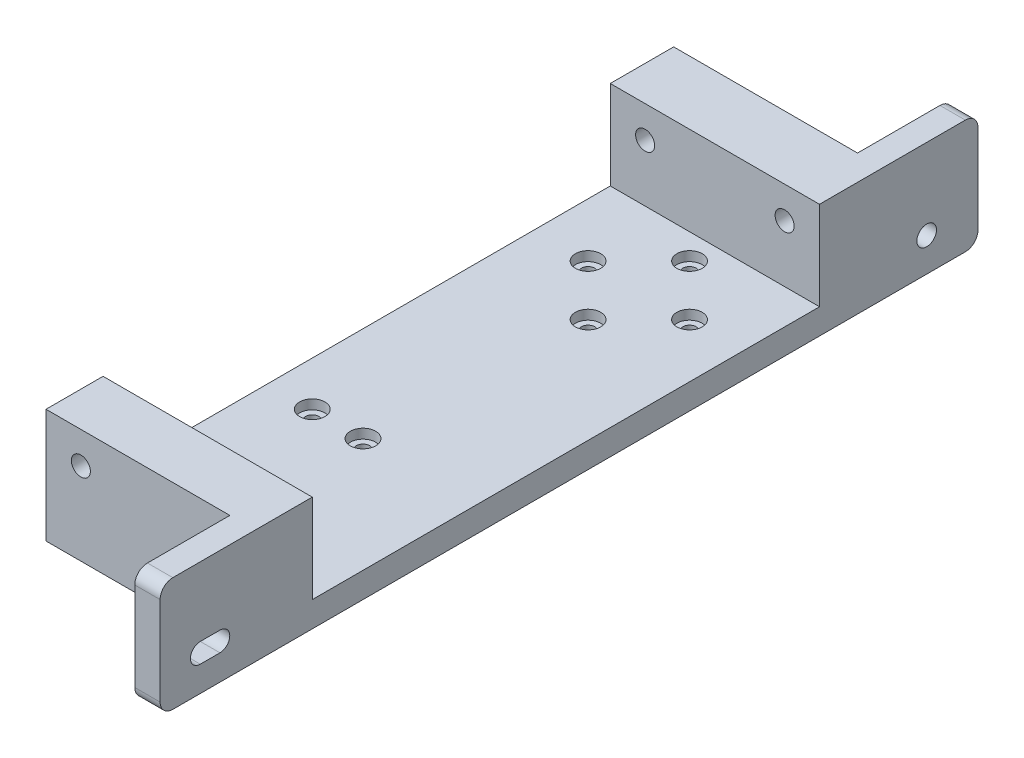
from build123d import *

# Parameters (mm, degrees)
SKETCH1_W            = 25
SKETCH1_H            = 34
BOSS_EXTRUDE2_DEPTH  = 4
SKETCH2_R            = 1.5
BOSS_EXTRUDE3_DEPTH  = 5
SKETCH3_R            = 1.5
BOSS_EXTRUDE4_DEPTH  = 2
SKETCH5_W            = 25
SKETCH5_H            = 4
BOSS_EXTRUDE5_DEPTH  = 55
SKETCH6_R            = 1.5
SKETCH6_W            = 25
SKETCH6_H            = 4
BOSS_EXTRUDE6_DEPTH  = 4
SKETCH7_W            = 4
SKETCH7_H            = 80
BOSS_EXTRUDE7_DEPTH  = 4
CUT_EXTRUDE2_DEPTH   = 5
SKETCH10_R           = 2
CUT_EXTRUDE3_DEPTH   = 1.5
SKETCH11_R           = 2
CUT_EXTRUDE4_DEPTH   = 1.5
SKETCH14_W           = 20
SKETCH14_H           = 18
BOSS_EXTRUDE8_DEPTH  = 4
SKETCH15_W           = 5
SKETCH15_H           = 18
BOSS_EXTRUDE9_DEPTH  = 29
SKETCH6_3_R          = 1.5
CUT_EXTRUDE5_DEPTH   = 35
FILLET2_R            = 2
SKETCH16_W           = 20
SKETCH16_H           = 18
BOSS_EXTRUDE10_DEPTH = 4
BOSS_EXTRUDE11_REACH = 35
SKETCH17_W           = 5
SKETCH17_H           = 18
FILLET3_R            = 2
SKETCH18_R           = 1.55
CUT_EXTRUDE6_DEPTH   = 5


with BuildPart() as part:
    # Sketch1 → Boss-Extrude2 (new body)
    with BuildSketch(Plane(origin=(0, 0, 0), x_dir=(1, 0, 0), z_dir=(0, 1, 0))):
        with Locations((12.5, -17)):
            Rectangle(SKETCH1_W, SKETCH1_H)
        with BuildLine():
            ThreePointArc((20.5, -15.95), (19.45, -17), (20.5, -18.05))
            ThreePointArc((20.5, -18.05), (21.55, -17), (20.5, -15.95))
        make_face(mode=Mode.SUBTRACT)
        with BuildLine():
            ThreePointArc((12.5, -26.05), (13.55, -25), (12.5, -23.95))
            ThreePointArc((12.5, -23.95), (11.45, -25), (12.5, -26.05))
        make_face(mode=Mode.SUBTRACT)
        with BuildLine():
            ThreePointArc((4.5, -15.95), (3.45, -17), (4.5, -18.05))
            ThreePointArc((4.5, -18.05), (5.55, -17), (4.5, -15.95))
        make_face(mode=Mode.SUBTRACT)
        with BuildLine():
            ThreePointArc((12.5, -7.95), (11.45, -9), (12.5, -10.05))
            ThreePointArc((12.5, -10.05), (13.55, -9), (12.5, -7.95))
        make_face(mode=Mode.SUBTRACT)
    extrude(amount=BOSS_EXTRUDE2_DEPTH)

    # Sketch2 → Boss-Extrude3 (add)
    with BuildSketch(Plane(origin=(0, 0, 0), x_dir=(-1, 0, 0), z_dir=(0, 0, -1))):
        Polygon((-25, 0), (0, 0), (4, 0), (4, 18), (-29, 18), (-29, 0), align=None)
        with Locations((-23.5, 13)):
            Circle(SKETCH2_R, mode=Mode.SUBTRACT)
        with Locations((-1.5, 13)):
            Circle(SKETCH2_R, mode=Mode.SUBTRACT)
    extrude(amount=-BOSS_EXTRUDE3_DEPTH)

    # Sketch3 → Boss-Extrude4 (add)
    with BuildSketch(Plane(origin=(0, 0, 0), x_dir=(-1, 0, 0), z_dir=(0, 0, -1))):
        with Locations((-1.5, 13)):
            Circle(SKETCH3_R)
        with Locations((-23.5, 13)):
            Circle(SKETCH3_R)
    extrude(amount=-BOSS_EXTRUDE4_DEPTH)

    # Sketch5 → Boss-Extrude5 (add)
    with BuildSketch(Plane.XY.offset(34)):
        with Locations((12.5, 2)):
            Rectangle(SKETCH5_W, SKETCH5_H)
    extrude(amount=BOSS_EXTRUDE5_DEPTH)

    # Sketch6 → Boss-Extrude6 (add)
    with BuildSketch(Plane.XY.offset(89)):
        Polygon((-4, 18), (29, 18), (29, 0), (25, 0), (25, 4), (0, 4), (0, 0), (-4, 0), align=None)
        with Locations((23.5, 13)):
            Circle(SKETCH6_R, mode=Mode.SUBTRACT)
        with Locations((1.5, 13)):
            Circle(SKETCH6_R, mode=Mode.SUBTRACT)
        with Locations((12.5, 2)):
            Rectangle(SKETCH6_W, SKETCH6_H)
    extrude(amount=-BOSS_EXTRUDE6_DEPTH)

    # Sketch7 → Boss-Extrude7 (add)
    with BuildSketch(Plane(origin=(0, 0, 0), x_dir=(-1, 0, 0), z_dir=(0, -1, 0))):
        with Locations((2, -45)):
            Rectangle(SKETCH7_W, SKETCH7_H)
        with Locations((-27, -45)):
            Rectangle(SKETCH7_W, SKETCH7_H)
    extrude(amount=-BOSS_EXTRUDE7_DEPTH)

    # Sketch9 → Cut-Extrude2 (cut, through all)
    with BuildSketch(Plane(origin=(0, 4, 0), x_dir=(1, 0, 0), z_dir=(0, 1, 0))):
        with BuildLine():
            ThreePointArc((1.95, -59), (3, -60.05), (4.05, -59))
            ThreePointArc((4.05, -59), (3, -57.95), (1.95, -59))
        make_face()
        with BuildLine():
            ThreePointArc((12.05, -59), (11, -57.95), (9.95, -59))
            ThreePointArc((9.95, -59), (11, -60.05), (12.05, -59))
        make_face()
        with BuildLine():
            ThreePointArc((12.05, -75), (11, -73.95), (9.95, -75))
            ThreePointArc((9.95, -75), (11, -76.05), (12.05, -75))
        make_face()
        with BuildLine():
            ThreePointArc((4.05, -75), (3, -73.95), (1.95, -75))
            ThreePointArc((1.95, -75), (3, -76.05), (4.05, -75))
        make_face()
    extrude(amount=-CUT_EXTRUDE2_DEPTH, mode=Mode.SUBTRACT)

    # Sketch10 → Cut-Extrude3 (cut)
    with BuildSketch(Plane(origin=(0, 4, 0), x_dir=(1, 0, 0), z_dir=(0, 1, 0))):
        with Locations((11, -75)):
            Circle(SKETCH10_R)
        with Locations((3, -75)):
            Circle(SKETCH10_R)
        with Locations((11, -59)):
            Circle(SKETCH10_R)
        with Locations((3, -59)):
            Circle(SKETCH10_R)
    extrude(amount=-CUT_EXTRUDE3_DEPTH, mode=Mode.SUBTRACT)

    # Sketch11 → Cut-Extrude4 (cut)
    with BuildSketch(Plane(origin=(0, 4, 0), x_dir=(1, 0, 0), z_dir=(0, 1, 0))):
        with Locations((4.5, -17)):
            Circle(SKETCH11_R)
        with Locations((12.5, -25)):
            Circle(SKETCH11_R)
        with Locations((20.5, -17)):
            Circle(SKETCH11_R)
        with Locations((12.5, -9)):
            Circle(SKETCH11_R)
    extrude(amount=-CUT_EXTRUDE4_DEPTH, mode=Mode.SUBTRACT)

    # Sketch14 → Boss-Extrude8 (add)
    with BuildSketch(Plane(origin=(29, 0, 0), x_dir=(0, 0, -1), z_dir=(1, 0, 0))):
        with Locations((-99, 9)):
            Rectangle(SKETCH14_W, SKETCH14_H)
        with BuildLine():
            Line((-102.666213823, 7.113305627), (-99.566213823, 7.113305627))
            ThreePointArc((-99.566213823, 7.113305627), (-98.016213823, 5.563305627), (-99.566213823, 4.013305627))
            Line((-99.566213823, 4.013305627), (-102.666213823, 4.013305627))
            ThreePointArc((-102.666213823, 4.013305627), (-104.216213823, 5.563305627), (-102.666213823, 7.113305627))
        make_face(mode=Mode.SUBTRACT)
    extrude(amount=-BOSS_EXTRUDE8_DEPTH)

    # Sketch15 → Boss-Extrude9 (add)
    with BuildSketch(Plane.ZY.offset(4)):
        with Locations((91.5, 9)):
            Rectangle(SKETCH15_W, SKETCH15_H)
    extrude(amount=-BOSS_EXTRUDE9_DEPTH)

    # Sketch6_3 → Cut-Extrude5 (cut)
    with BuildSketch(Plane.XY.offset(89)):
        with Locations((23.5, 13)):
            Circle(SKETCH6_3_R)
        with Locations((1.5, 13)):
            Circle(SKETCH6_3_R)
    extrude(amount=CUT_EXTRUDE5_DEPTH, mode=Mode.SUBTRACT)

    # Fillet2
    fillet2_edges = [part.edges().sort_by_distance(p)[0] for p in [
        (27, 18, 109),
        (27, 0, 109),
    ]]
    fillet(fillet2_edges, radius=FILLET2_R)

    # Sketch16 → Boss-Extrude10 (add)
    with BuildSketch(Plane(origin=(29, 0, 0), x_dir=(0, 0, -1), z_dir=(1, 0, 0))):
        with Locations((10, 9)):
            Rectangle(SKETCH16_W, SKETCH16_H)
    extrude(amount=-BOSS_EXTRUDE10_DEPTH)

    # Sketch17 → Boss-Extrude11 (add, up to next)
    with BuildSketch(Plane.ZY.offset(4), mode=Mode.PRIVATE) as boss_extrude11_sk1:
        with Locations((-2.5, 9)):
            Rectangle(SKETCH17_W, SKETCH17_H)
    boss_extrude11_tool1 = extrude(boss_extrude11_sk1.sketch, amount=-BOSS_EXTRUDE11_REACH, mode=Mode.PRIVATE) - part.part
    add(boss_extrude11_tool1.solids().sort_by_distance((-4, 9, -2.5))[0])

    # Fillet3
    fillet3_edges = [part.edges().sort_by_distance(p)[0] for p in [
        (27, 18, -20),
        (27, 0, -20),
    ]]
    fillet(fillet3_edges, radius=FILLET3_R)

    # Sketch18 → Cut-Extrude6 (cut, through all)
    with BuildSketch(Plane.ZY.offset(-25)):
        with Locations((-11.904808502, 5.295848229)):
            Circle(SKETCH18_R)
    extrude(amount=-CUT_EXTRUDE6_DEPTH, mode=Mode.SUBTRACT)


solid = part.part
